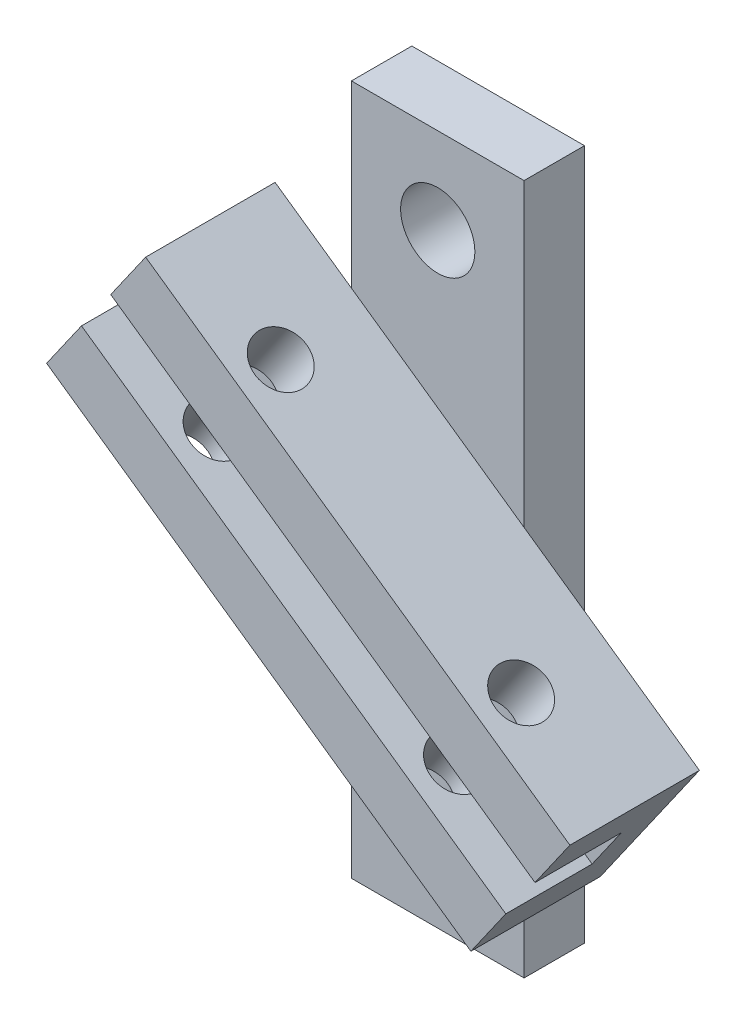
from build123d import *

# Parameters (mm, degrees)
SKIZZE1_W                       = 20
SKIZZE1_H                       = 80
SKIZZE1_R                       = 4.3
AUFSATZ_LINEAR_AUSTRAGEN1_DEPTH = 7
AUFSATZ_LINEAR_AUSTRAGEN2_DEPTH = 15
SCHNITT_LINEAR_AUSTRAGEN1_DEPTH = 10
F_6_0_6_DURCHMESSER_BOHRUNG1_D  = 6


with BuildPart() as part:
    # Skizze1 → Aufsatz-Linear austragen1 (new body)
    with BuildSketch(Plane.XY):
        with Locations((10, 40)):
            Rectangle(SKIZZE1_W, SKIZZE1_H)
        with Locations((10, 70)):
            Circle(SKIZZE1_R, mode=Mode.SUBTRACT)
        with Locations(Location((10, 10, 0), (0, 0, 180))):  # turned: the seam where the file's is
            Circle(SKIZZE1_R, mode=Mode.SUBTRACT)
    extrude(amount=AUFSATZ_LINEAR_AUSTRAGEN1_DEPTH)

    # Skizze2 → Aufsatz-Linear austragen2 (add)
    with BuildSketch(Plane.XY.offset(7)):
        Polygon((32.882510841, 20.376208379), (20, 29.396639581), (20, 20.79017873), (28.838796965, 14.601186467), align=None)
        Polygon((36.266611816, 25.20920544), (20, 36.599209655), (20, 29.396639581), (32.882510841, 20.376208379), align=None)
        Polygon((40.310325692, 30.984227352), (20, 45.205670506), (20, 36.599209655), (36.266611816, 25.20920544), align=None)
        Polygon((20, 45.205670506), (0, 59.20982127), (0, 50.603360419), (20, 36.599209655), align=None)
        Polygon((20, 36.599209655), (0, 50.603360419), (0, 43.400790345), (20, 29.396639581), align=None)
        Polygon((20, 29.396639581), (0, 43.400790345), (0, 34.794329494), (20, 20.79017873), align=None)
        Polygon((0, 43.400790345), (-16.266611816, 54.79079456), (-20.310325692, 49.015772648), (0, 34.794329494), align=None)
        Polygon((0, 50.603360419), (-12.882510841, 59.623791621), (-16.266611816, 54.79079456), (0, 43.400790345), align=None)
        Polygon((0, 59.20982127), (-8.838796965, 65.398813533), (-12.882510841, 59.623791621), (0, 50.603360419), align=None)
    extrude(amount=AUFSATZ_LINEAR_AUSTRAGEN2_DEPTH)

    # Skizze3 → Schnitt-Linear austragen1 (cut)
    with BuildSketch(Plane.XY.offset(22)):
        Polygon((-16.266611816, 54.79079456), (32.882510841, 20.376208379), (36.266611816, 25.20920544), (-12.882510841, 59.623791621), align=None)
    extrude(amount=-SCHNITT_LINEAR_AUSTRAGEN1_DEPTH, mode=Mode.SUBTRACT)

    # Ø6.0 (6) Durchmesser Bohrung1 (through all)
    with Locations(Plane(origin=(27.819516063, 39.730386413, 0), x_dir=(0.819152044, -0.573576436, 0), z_dir=(0.573576436, 0.819152044, 0))):
        with Locations((2.248462989, -17), (-31.751537011, -17)):
            Hole(F_6_0_6_DURCHMESSER_BOHRUNG1_D / 2)


solid = part.part
